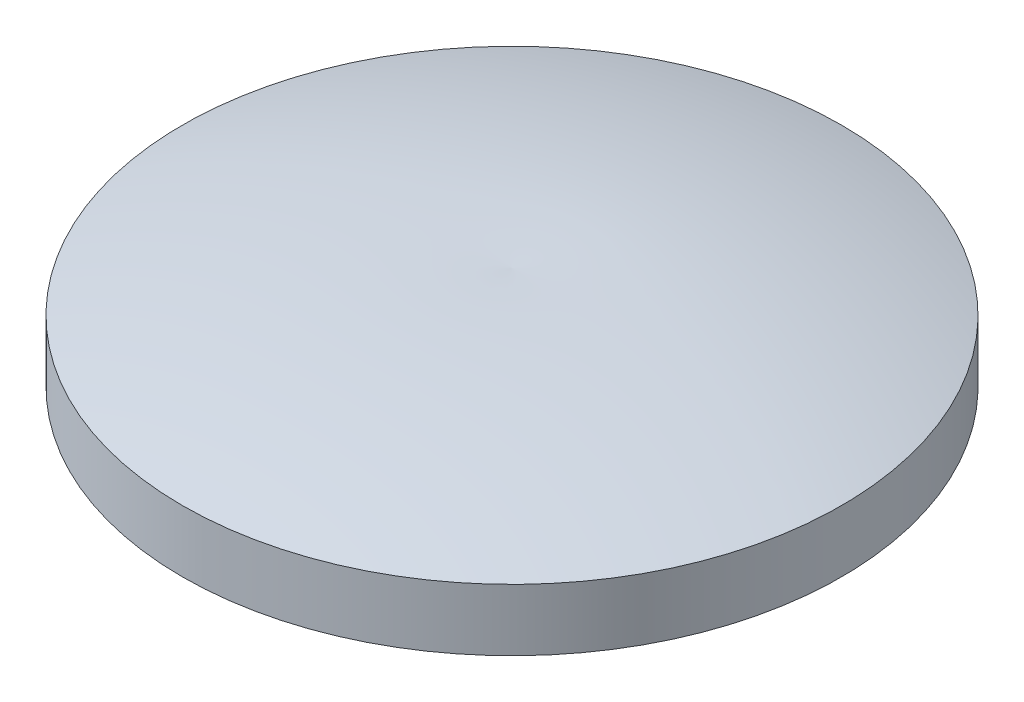
from build123d import *


with BuildPart() as part:
    # Sketch1 → Revolve1 (revolve)
    with BuildSketch(Plane.XY):
        with BuildLine():
            Line((0, 0), (0, 6.35))
            ThreePointArc((0, 6.35), (-10.274695316, 5.99756253), (-20.32, 3.81))
            Line((-20.32, 3.81), (-20.32, 0))
            Line((-20.32, 0), (0, 0))
        make_face()
    revolve(axis=Axis((0, 0, 0), (0, 1, 0)))


solid = part.part
